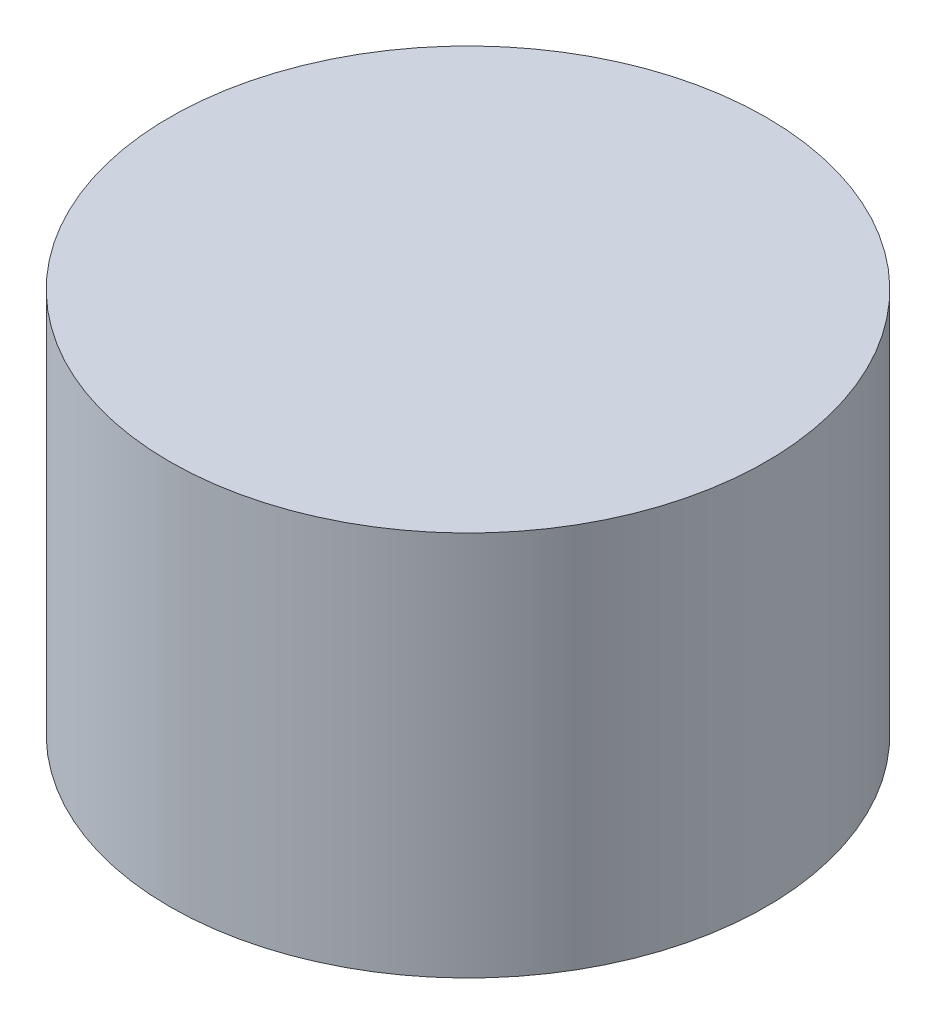
from build123d import *

# Parameters (mm, degrees)
SKETCH1_R           = 4.914519
BOSS_EXTRUDE1_DEPTH = 6.35


with BuildPart() as part:
    # Sketch1 → Boss-Extrude1 (new body)
    with BuildSketch(Plane(origin=(0, 0, 0), x_dir=(1, 0, 0), z_dir=(0, 1, 0))):
        Circle(SKETCH1_R)
    extrude(amount=BOSS_EXTRUDE1_DEPTH)


solid = part.part
